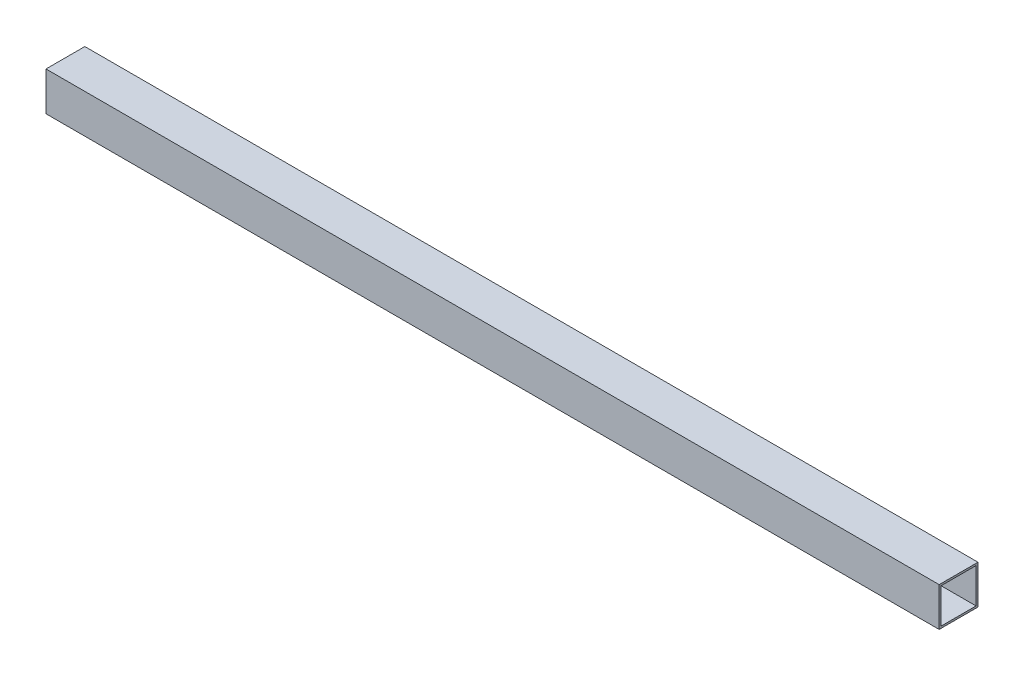
from build123d import *

# Parameters (mm, degrees)
CROQUIS1_W              = 40
CROQUIS1_H              = 40
CROQUIS1_W_2            = 36
CROQUIS1_H_2            = 36
SALIENTE_EXTRUIR1_DEPTH = 920


with BuildPart() as part:
    # Croquis1 → Saliente-Extruir1 (new body)
    with BuildSketch(Plane(origin=(0, 0, 0), x_dir=(0, 0, -1), z_dir=(1, 0, 0))):
        Rectangle(CROQUIS1_W, CROQUIS1_H)
        Rectangle(CROQUIS1_W_2, CROQUIS1_H_2, mode=Mode.SUBTRACT)
    extrude(amount=SALIENTE_EXTRUIR1_DEPTH)


solid = part.part
